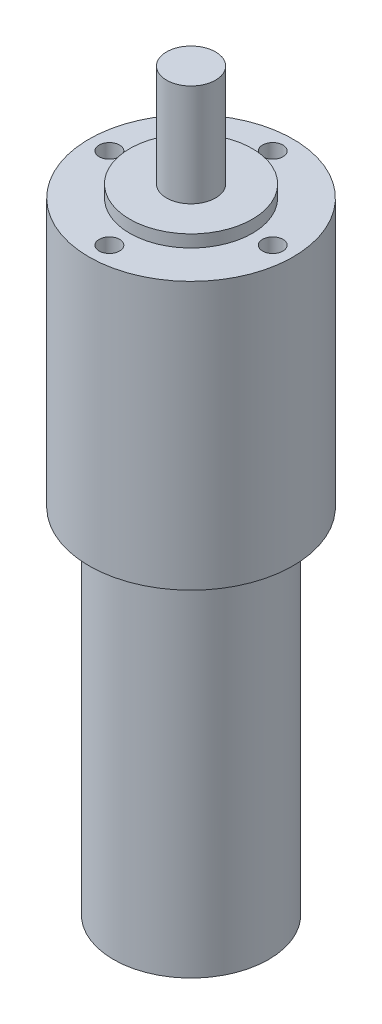
from build123d import *

# Parameters (mm, degrees)
SKETCH1_R           = 25
BOSS_EXTRUDE1_DEPTH = 65.5
SKETCH2_R           = 15
BOSS_EXTRUDE2_DEPTH = 3
SKETCH3_R           = 6
BOSS_EXTRUDE3_DEPTH = 25
SKETCH4_R           = 19
BOSS_EXTRUDE4_DEPTH = 86.5
SKETCH5_R           = 2.5
CUT_EXTRUDE1_DEPTH  = 10


with BuildPart() as part:
    # Sketch1 → Boss-Extrude1 (new body)
    with BuildSketch(Plane(origin=(0, 0, 0), x_dir=(1, 0, 0), z_dir=(0, 1, 0))):
        Circle(SKETCH1_R)
    extrude(amount=BOSS_EXTRUDE1_DEPTH)

    # Sketch2 → Boss-Extrude2 (add)
    with BuildSketch(Plane(origin=(0, 65.5, 0), x_dir=(1, 0, 0), z_dir=(0, 1, 0))):
        Circle(SKETCH2_R)
    extrude(amount=BOSS_EXTRUDE2_DEPTH)

    # Sketch3 → Boss-Extrude3 (add)
    with BuildSketch(Plane(origin=(0, 68.5, 0), x_dir=(1, 0, 0), z_dir=(0, 1, 0))):
        Circle(SKETCH3_R)
    extrude(amount=BOSS_EXTRUDE3_DEPTH)

    # Sketch4 → Boss-Extrude4 (add)
    with BuildSketch(Plane.XZ):
        Circle(SKETCH4_R)
    extrude(amount=BOSS_EXTRUDE4_DEPTH)

    # Sketch5 → Cut-Extrude1 (cut)
    with BuildSketch(Plane(origin=(0, 65.5, 0), x_dir=(1, 0, 0), z_dir=(0, 1, 0))):
        with Locations((0, 20)):
            Circle(SKETCH5_R)
        with Locations((20, 0)):
            Circle(SKETCH5_R)
        with Locations((0, -20)):
            Circle(SKETCH5_R)
        with Locations((-20, 0)):
            Circle(SKETCH5_R)
    extrude(amount=-CUT_EXTRUDE1_DEPTH, mode=Mode.SUBTRACT)


solid = part.part
